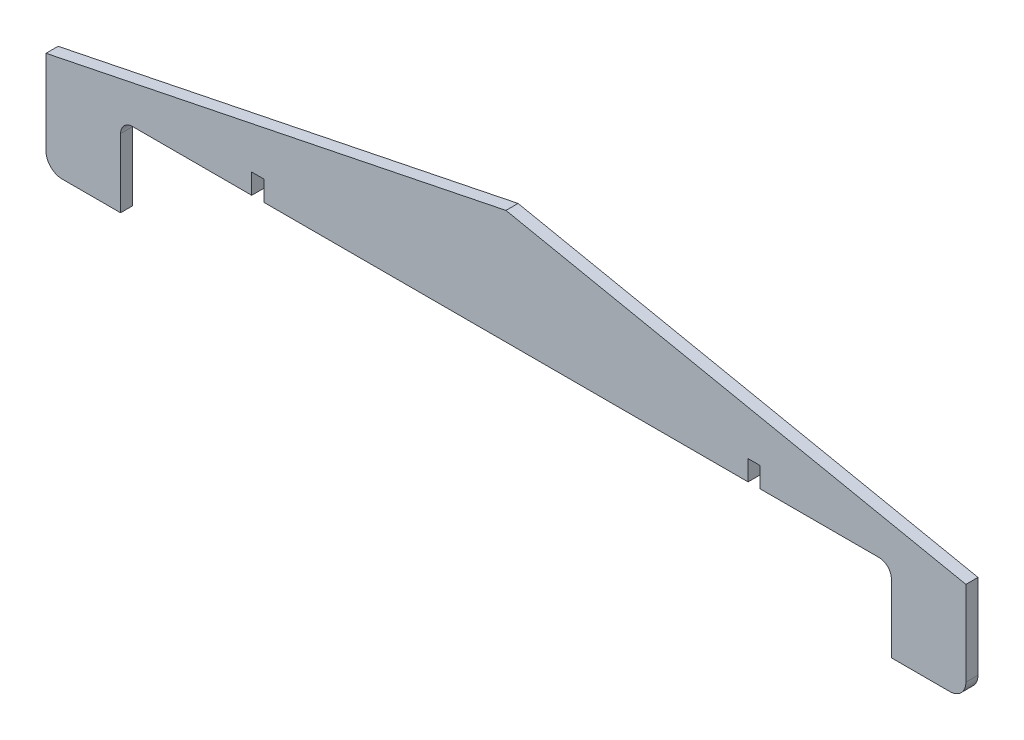
from build123d import *

# Parameters (mm, degrees)
BOSS_EXTRUDE1_DEPTH = 3
SKETCH2_W           = 191
SKETCH2_H           = 40
CUT_EXTRUDE1_DEPTH  = 4
FILLET1_R           = 3
SKETCH3_W           = 3
SKETCH3_H           = 10
CUT_EXTRUDE2_DEPTH  = 4
FILLET2_R           = 4
BOSS_EXTRUDE2_DEPTH = 3


with BuildPart() as part:
    # Sketch1 → Boss-Extrude1 (new body)
    with BuildSketch(Plane.XY):
        Polygon((-16, 19.999811529), (16, 19.999811529), (113.979628183, 0), (113.979628183, -25), (-113.979628183, -25), (-113.979628183, 0), align=None)
    extrude(amount=BOSS_EXTRUDE1_DEPTH)

    # Sketch2 → Cut-Extrude1 (cut, through all)
    with BuildSketch(Plane.XY.offset(3)):
        with Locations((0, -25)):
            Rectangle(SKETCH2_W, SKETCH2_H)
    extrude(amount=-CUT_EXTRUDE1_DEPTH, mode=Mode.SUBTRACT)

    # Fillet1
    fillet1_edges = [part.edges().sort_by_distance(p)[0] for p in [
        (95.5, -5, 1.5),
        (-95.5, -5, 1.5),
    ]]
    fillet(fillet1_edges, radius=FILLET1_R)

    # Sketch3 → Cut-Extrude2 (cut, through all)
    with BuildSketch(Plane.XY.offset(3)):
        with Locations((-61.5, -5)):
            Rectangle(SKETCH3_W, SKETCH3_H)
        with Locations((61.5, -5)):
            Rectangle(SKETCH3_W, SKETCH3_H)
    extrude(amount=-CUT_EXTRUDE2_DEPTH, mode=Mode.SUBTRACT)

    # Fillet2
    fillet2_edges = [part.edges().sort_by_distance(p)[0] for p in [
        (113.979628183, -25, 1.5),
        (-113.979628183, -25, 1.5),
    ]]
    fillet(fillet2_edges, radius=FILLET2_R)

    # Sketch4 → Boss-Extrude2 (add)
    with BuildSketch(Plane.XY.offset(3)):
        Polygon((-26.29440044, 17.898496465), (0, 23.265765793), (26.811324143, 17.792980892), align=None)
    extrude(amount=-BOSS_EXTRUDE2_DEPTH)


solid = part.part
